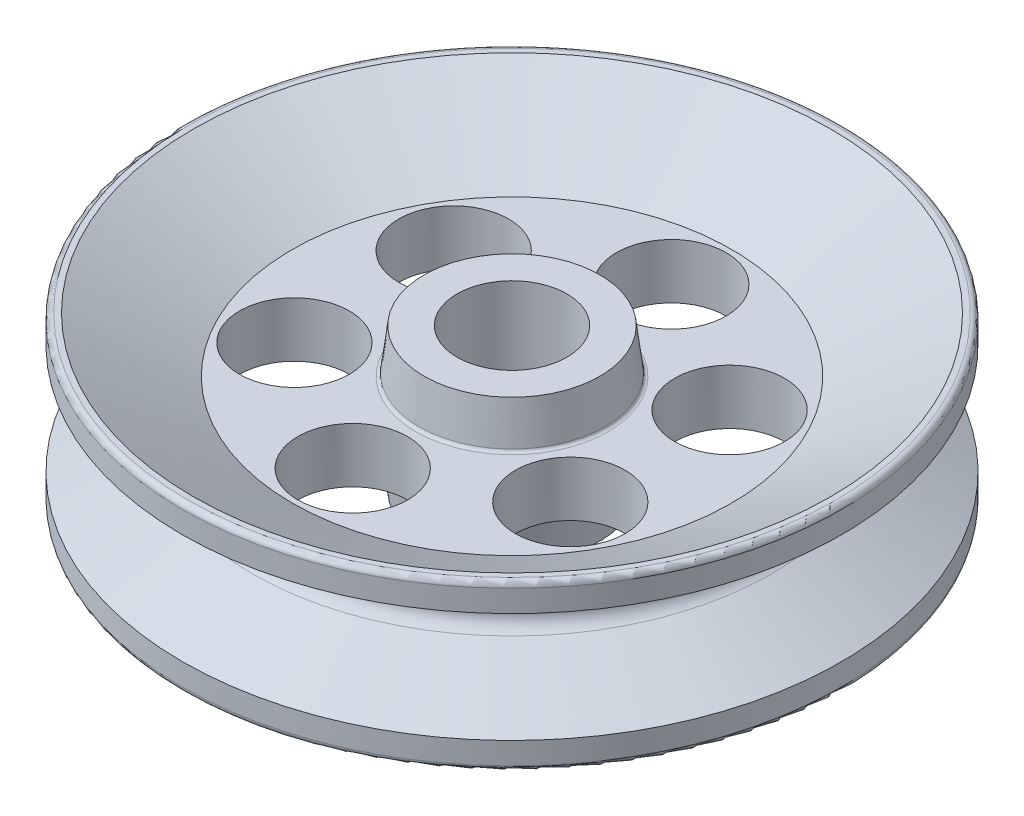
from build123d import *

# Parameters (mm, degrees)
SKETCH1_R           = 1524
BOSS_EXTRUDE1_DEPTH = 381
SKETCH3_R           = 254
CUT_EXTRUDE1_DEPTH  = 763
SKETCH4_R           = 254
CUT_EXTRUDE2_DEPTH  = 763
CIRPATTERN1_COUNT   = 6
FILLET3_R           = 25.4


with BuildPart() as part:
    # Sketch1 → Boss-Extrude1 (new body, symmetric)
    with BuildSketch(Plane(origin=(0, 0, 0), x_dir=(1, 0, 0), z_dir=(0, 1, 0))):
        Circle(SKETCH1_R)
    extrude(amount=BOSS_EXTRUDE1_DEPTH, both=True)

    # Sketch2 → Cut-Revolve1 (revolve, cut)
    with BuildSketch(Plane(origin=(0, 0, 0), x_dir=(0, 0, -1), z_dir=(1, 0, 0))):
        with BuildLine():
            Line((1524, -254), (1524, 254))
            Line((1524, 254), (1198.359094878, 65.991135768))
            ThreePointArc((1198.359094878, 65.991135768), (1160.259094878, 0), (1198.359094878, -65.991135768))
            Line((1198.359094878, -65.991135768), (1524, -254))
        make_face()
    revolve(axis=Axis((0, 381, 0), (0, -1, 0)), mode=Mode.SUBTRACT)

    # Sketch3 → Cut-Extrude1 (cut, through all)
    with BuildSketch(Plane(origin=(0, 381, 0), x_dir=(1, 0, 0), z_dir=(0, 1, 0))):
        Circle(SKETCH3_R)
    extrude(amount=-CUT_EXTRUDE1_DEPTH, mode=Mode.SUBTRACT)

    # Sketch4 → Cut-Extrude2 (cut, through all)
    with BuildSketch(Plane(origin=(0, 381, 0), x_dir=(1, 0, 0), z_dir=(0, 1, 0))):
        with Locations((0, 736.6)):
            Circle(SKETCH4_R)
    cut_extrude2 = extrude(amount=-CUT_EXTRUDE2_DEPTH, mode=Mode.SUBTRACT)

    # CirPattern1: Cut-Extrude2 ×6 about axis
    cirpattern1_axis = Axis((0, 0, 0), (0, 1, 0))
    for i in range(1, CIRPATTERN1_COUNT):
        add(cut_extrude2.rotate(cirpattern1_axis, i * 360 / CIRPATTERN1_COUNT), mode=Mode.SUBTRACT)

    # Sketch7 → Cut-Revolve3 (revolve, cut)
    with BuildSketch(Plane(origin=(0, 0, 0), x_dir=(0, 0, -1), z_dir=(1, 0, 0))):
        with BuildLine():
            Line((406.4, 330.2), (430.137519746, 139.684026625))
            ThreePointArc((430.137519746, 139.684026625), (434.919220146, 130.62494696), (444.5, 127))
            Line((444.5, 127), (1016, 127))
            Line((1016, 127), (1473.2, 381))
            Line((1473.2, 381), (0, 381))
            Line((0, 381), (0, 330.2))
            Line((0, 330.2), (406.4, 330.2))
        make_face()
        with BuildLine():
            Line((0, -330.2), (0, -381))
            Line((0, -381), (1473.2, -381))
            Line((1473.2, -381), (1016, -127))
            Line((1016, -127), (444.5, -127))
            ThreePointArc((444.5, -127), (434.919220146, -130.62494696), (430.137519746, -139.684026625))
            Line((430.137519746, -139.684026625), (406.4, -330.2))
            Line((406.4, -330.2), (0, -330.2))
        make_face()
    revolve(axis=Axis((0, 254, 0), (0, 1, 0)), mode=Mode.SUBTRACT)

    # Fillet3
    fillet3_edges = [part.edges().sort_by_distance(p)[0] for p in [
        (-1524, -381, 0),
        (-1524, 381, 0),
    ]]
    fillet(fillet3_edges, radius=FILLET3_R)


solid = part.part
